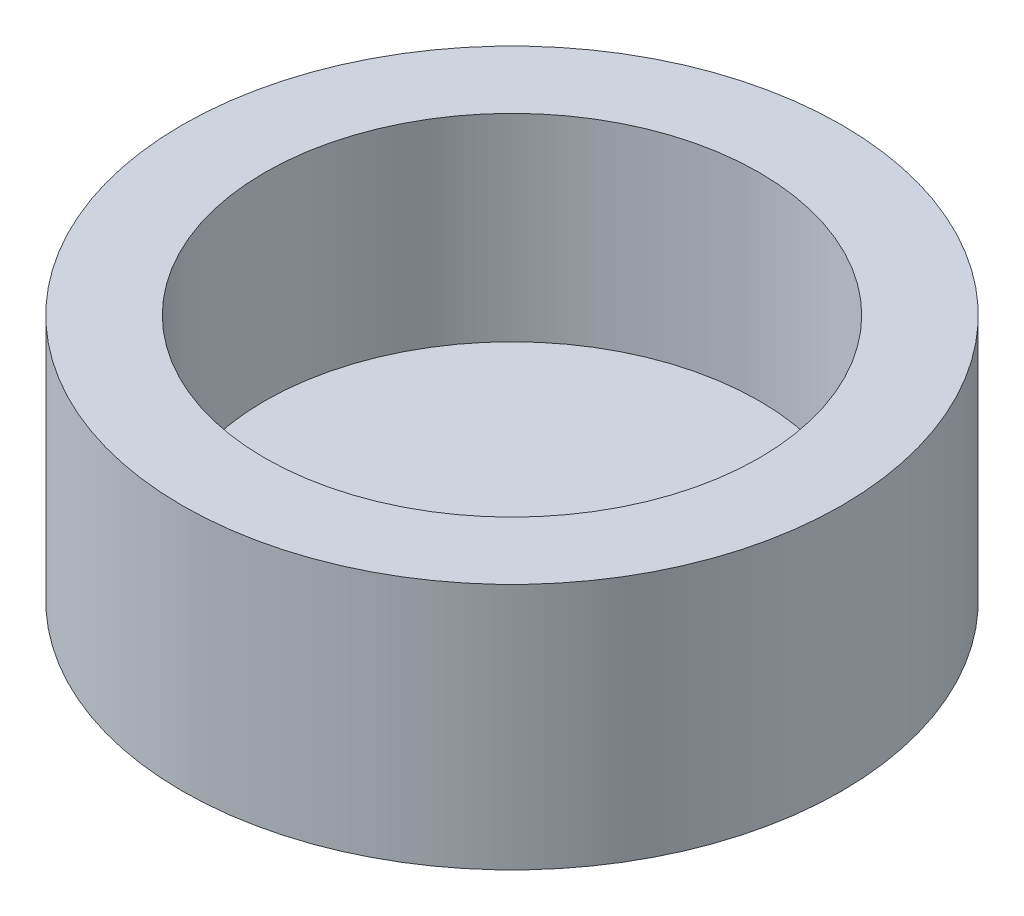
from build123d import *

# Parameters (mm, degrees)
SKETCH1_R           = 25.4
BOSS_EXTRUDE1_DEPTH = 19.05
SKETCH2_R           = 19.05
CUT_EXTRUDE1_DEPTH  = 15.24


with BuildPart() as part:
    # Sketch1 → Boss-Extrude1 (new body)
    with BuildSketch(Plane(origin=(0, 0, 0), x_dir=(1, 0, 0), z_dir=(0, 1, 0))):
        Circle(SKETCH1_R)
    extrude(amount=BOSS_EXTRUDE1_DEPTH)

    # Sketch2 → Cut-Extrude1 (cut)
    with BuildSketch(Plane(origin=(0, 19.05, 0), x_dir=(1, 0, 0), z_dir=(0, 1, 0))):
        Circle(SKETCH2_R)
    extrude(amount=-CUT_EXTRUDE1_DEPTH, mode=Mode.SUBTRACT)


solid = part.part
